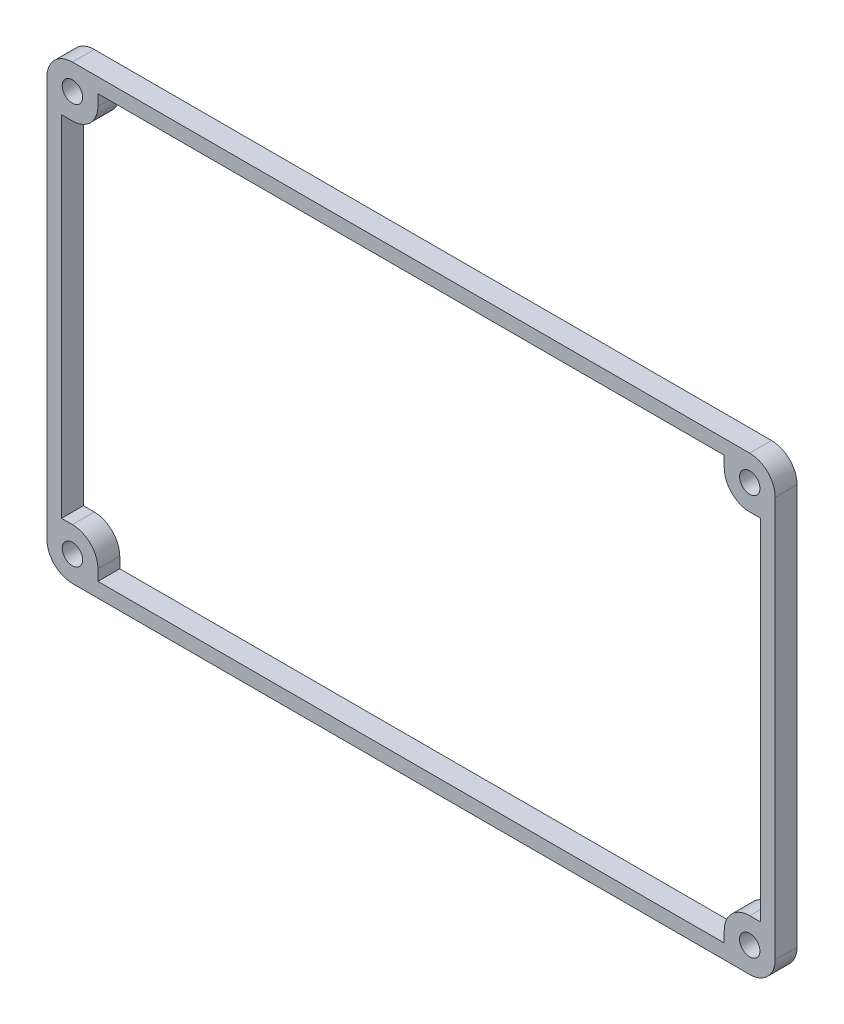
from build123d import *

# Parameters (mm, degrees)
SKETCH1_R           = 1.4
BOSS_EXTRUDE1_DEPTH = 3
SKETCH2_W           = 5
SKETCH2_H           = 48
SKETCH2_W_2         = 86
SKETCH2_H_2         = 5
CUT_EXTRUDE1_DEPTH  = 3
FILLET1_R           = 3.5


with BuildPart() as part:
    # Sketch1 → Boss-Extrude1 (new body)
    with BuildSketch(Plane.XY):
        with BuildLine():
            Line((-46.5, -31), (46.5, -31))
            ThreePointArc((46.5, -31), (48.974873734, -29.974873734), (50, -27.5))
            Line((50, -27.5), (50, 27.5))
            ThreePointArc((50, 27.5), (48.974873734, 29.974873734), (46.5, 31))
            Line((46.5, 31), (-46.5, 31))
            ThreePointArc((-46.5, 31), (-48.974873734, 29.974873734), (-50, 27.5))
            Line((-50, 27.5), (-50, -27.5))
            ThreePointArc((-50, -27.5), (-48.974873734, -29.974873734), (-46.5, -31))
        make_face()
        with Locations((-46.5, 27.5)):
            Circle(SKETCH1_R, mode=Mode.SUBTRACT)
        with Locations((46.5, 27.5)):
            Circle(SKETCH1_R, mode=Mode.SUBTRACT)
        with Locations((46.5, -27.5)):
            Circle(SKETCH1_R, mode=Mode.SUBTRACT)
        with Locations((-46.5, -27.5)):
            Circle(SKETCH1_R, mode=Mode.SUBTRACT)
    extrude(amount=BOSS_EXTRUDE1_DEPTH)

    # Sketch2 → Cut-Extrude1 (cut)
    with BuildSketch(Plane.XY.offset(3)):
        with Locations((-45.5, 0)):
            Rectangle(SKETCH2_W, SKETCH2_H)
        Rectangle(SKETCH2_W_2, SKETCH2_H)
        with Locations((0, 26.5)):
            Rectangle(SKETCH2_W_2, SKETCH2_H_2)
        with Locations((45.5, 0)):
            Rectangle(SKETCH2_W, SKETCH2_H)
        with Locations((0, -26.5)):
            Rectangle(SKETCH2_W_2, SKETCH2_H_2)
    extrude(amount=-CUT_EXTRUDE1_DEPTH, mode=Mode.SUBTRACT)

    # Fillet1
    fillet1_edges = [part.edges().sort_by_distance(p)[0] for p in [
        (-43, 24, 1.5),
        (43, 24, 1.5),
        (43, -24, 1.5),
        (-43, -24, 1.5),
    ]]
    fillet(fillet1_edges, radius=FILLET1_R)


solid = part.part
